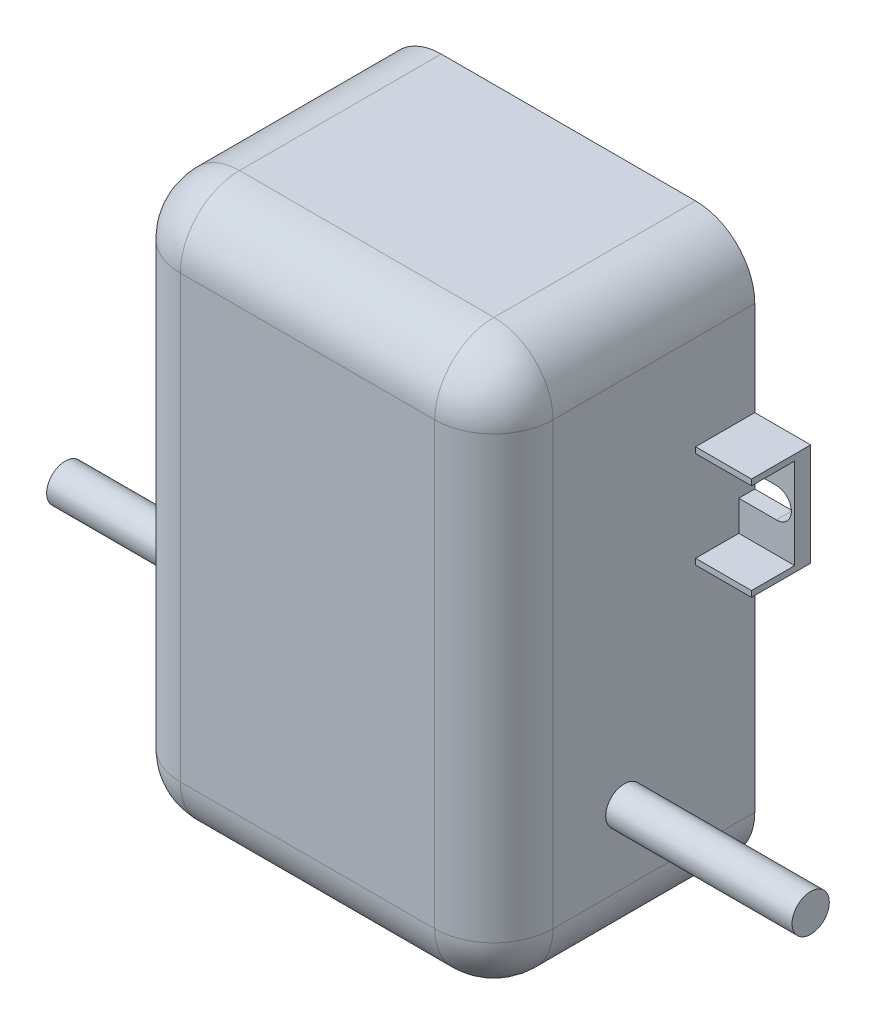
from build123d import *

# Parameters (mm, degrees)
SKETCH1_W           = 40
SKETCH1_H           = 60
BOSS_EXTRUDE1_DEPTH = 28
BOSS_EXTRUDE2_DEPTH = 6.35
FILLET1_R           = 6.35
SKETCH4_W           = 8.790315594
SKETCH4_H           = 9.73
CUT_EXTRUDE1_DEPTH  = 4.6355
SKETCH5_R           = 2
BOSS_EXTRUDE3_DEPTH = 40


with BuildPart() as part:
    # Sketch1 → Boss-Extrude1 (new body)
    with BuildSketch(Plane.XY):
        Rectangle(SKETCH1_W, SKETCH1_H)
    extrude(amount=BOSS_EXTRUDE1_DEPTH)

    # Sketch2 → Boss-Extrude2 (add)
    with BuildSketch(Plane(origin=(0, 0, 0), x_dir=(-1, 0, 0), z_dir=(0, 0, -1))):
        with BuildLine():
            Line((-20, 9.6), (-20, 13.5))
            Line((-20, 13.5), (-26, 13.5))
            Line((-26, 13.5), (-26, 2.5))
            Line((-26, 2.5), (-20, 2.5))
            Line((-20, 2.5), (-20, 6.4))
            Line((-20, 6.4), (-24.038303444, 6.4))
            ThreePointArc((-24.038303444, 6.4), (-25.638303444, 8), (-24.038303444, 9.6))
            Line((-24.038303444, 9.6), (-20, 9.6))
        make_face()
        with BuildLine():
            Line((24.038303444, 6.4), (20, 6.4))
            Line((20, 6.4), (20, 2.5))
            Line((20, 2.5), (26, 2.5))
            Line((26, 2.5), (26, 13.5))
            Line((26, 13.5), (20, 13.5))
            Line((20, 13.5), (20, 9.6))
            Line((20, 9.6), (24.038303444, 9.6))
            ThreePointArc((24.038303444, 9.6), (25.638303444, 8), (24.038303444, 6.4))
        make_face()
    extrude(amount=-BOSS_EXTRUDE2_DEPTH)

    # Fillet1
    fillet1_edges = [part.edges().sort_by_distance(p)[0] for p in [
        (-20, 0, 28),
        (0, -30, 28),
        (20, 0, 28),
        (0, 30, 28),
        (20, -30, 14),
        (-20, -30, 14),
        (-20, 30, 14),
        (20, 30, 14),
    ]]
    fillet(fillet1_edges, radius=FILLET1_R)

    # Sketch4 → Cut-Extrude1 (cut)
    with BuildSketch(Plane.XY.offset(6.35)):
        with Locations((-24.395157797, 8)):
            Rectangle(SKETCH4_W, SKETCH4_H)
        with Locations((24.395157797, 8)):
            Rectangle(SKETCH4_W, SKETCH4_H)
    extrude(amount=-CUT_EXTRUDE1_DEPTH, mode=Mode.SUBTRACT)

    # Sketch5 → Boss-Extrude3 (add, symmetric)
    with BuildSketch(Plane(origin=(0, 0, 0), x_dir=(0, 0, -1), z_dir=(1, 0, 0))):
        with Locations((-14, -16)):
            Circle(SKETCH5_R)
    extrude(amount=BOSS_EXTRUDE3_DEPTH, both=True)


solid = part.part
